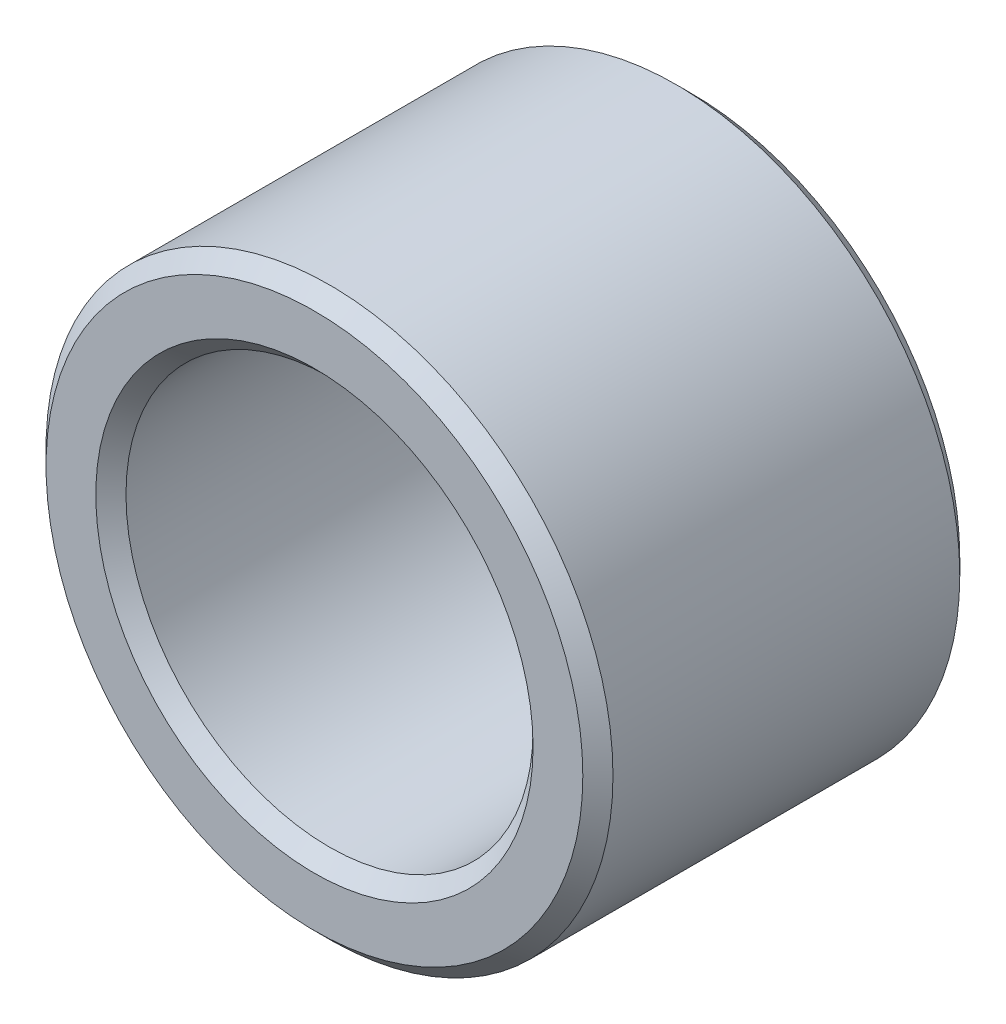
from build123d import *

# Parameters (mm, degrees)
SKETCH1_R      = 4.7752
SKETCH1_R_2    = 3.429
EXTRUDE1_DEPTH = 3.175
CHAMFER1_SIZE  = 0.254


with BuildPart() as part:
    # Sketch1 → Extrude1 (new body, symmetric)
    with BuildSketch(Plane.XY):
        Circle(SKETCH1_R)
        Circle(SKETCH1_R_2, mode=Mode.SUBTRACT)
    extrude(amount=EXTRUDE1_DEPTH, both=True)

    # Chamfer1
    chamfer1_edges = [part.edges().sort_by_distance(p)[0] for p in [
        (-4.7752, 0, -3.175),
        (-4.7752, 0, 3.175),
        (-3.429, 0, -3.175),
        (-3.429, 0, 3.175),
    ]]
    chamfer(chamfer1_edges, length=CHAMFER1_SIZE)


solid = part.part
